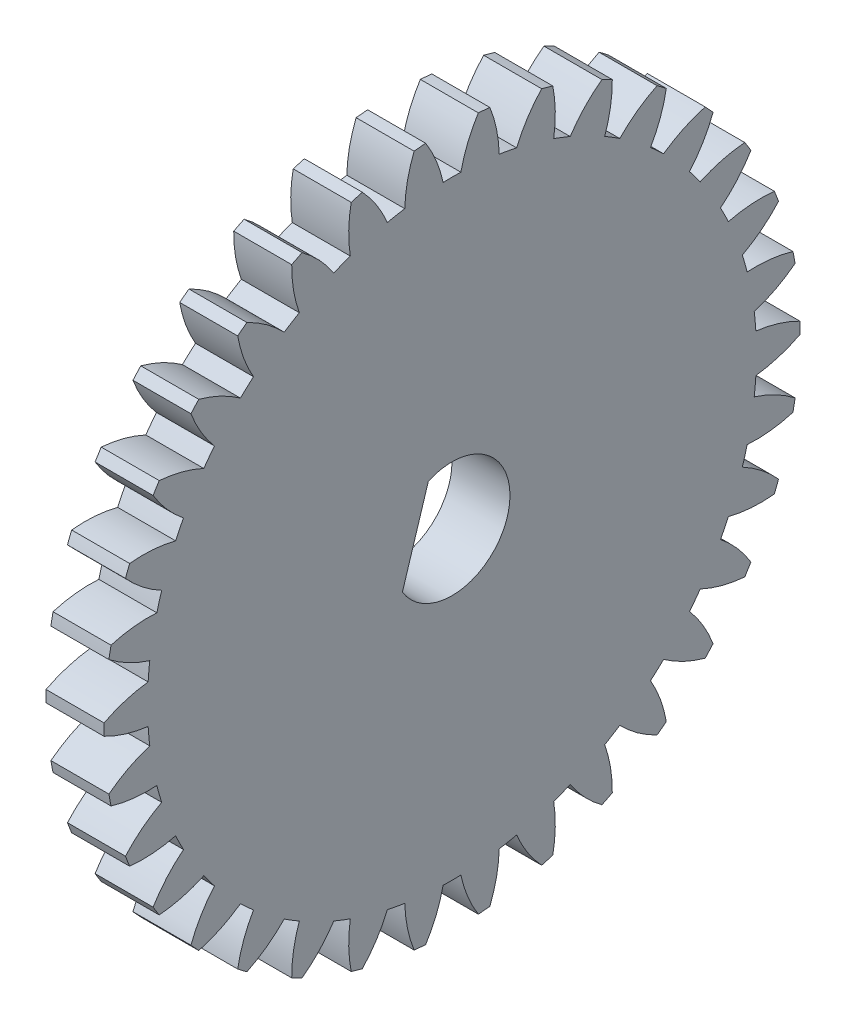
from build123d import *

# Parameters (mm, degrees)
BASPROSKE_W        = 3
BASPROSKE_H        = 18
TOOTHCUT_DEPTH     = 26.632011236
TEETHCUTS_COUNT    = 34
TEETHCUTS_ANGLE    = 349.411764706
CUT_EXTRUDE1_DEPTH = 26.595810004


with BuildPart() as part:
    # BasProSke → Base-Revolve (revolve)
    with BuildSketch(Plane(origin=(0, 0, 0), x_dir=(1, 0, 0), z_dir=(0, 1, 0)), mode=Mode.PRIVATE) as base_revolve_sk:
        with Locations((1.5, 9)):
            Rectangle(BASPROSKE_W, BASPROSKE_H)
    revolve(base_revolve_sk.sketch.rotate(Axis((-10, 0, 0), (1, 0, 0)), 180), axis=Axis((-10, 0, 0), (1, 0, 0)))

    # TooCutSke → ToothCut (cut, through all)
    with BuildSketch(Plane(origin=(0, 0, 0), x_dir=(0, 0, -1), z_dir=(1, 0, 0))):
        with BuildLine():
            ThreePointArc((0.458149848, 15.742334634), (0, 15.749), (-0.458149848, 15.742334634))
            ThreePointArc((-0.458149848, 15.742334634), (-0.818018246, 16.898604037), (-1.377276242, 17.972705843))
            ThreePointArc((-1.377276242, 17.972705843), (0, 18.0254), (1.377276242, 17.972705843))
            ThreePointArc((1.377276242, 17.972705843), (0.818018246, 16.898604037), (0.458149848, 15.742334634))
        make_face()
    toothcut = extrude(amount=TOOTHCUT_DEPTH, mode=Mode.SUBTRACT)

    # TeethCuts: ToothCut ×34 about axis
    teethcuts_axis = Axis((-10, 0, 0), (1, 0, 0))
    for i in range(1, TEETHCUTS_COUNT):
        add(toothcut.rotate(teethcuts_axis, i * TEETHCUTS_ANGLE / (TEETHCUTS_COUNT - 1)), mode=Mode.SUBTRACT)

    # Sketch1 → Cut-Extrude1 (cut, through all)
    with BuildSketch(Plane(origin=(3, 0, 0), x_dir=(0, 0, -1), z_dir=(1, 0, 0))):
        with BuildLine():
            Line((-1.223161853, 2.739320186), (-2.564939759, -1.555983301))
            ThreePointArc((-2.564939759, -1.555983301), (2.863535658, -0.894518604), (-1.223161853, 2.739320186))
        make_face()
    extrude(amount=-CUT_EXTRUDE1_DEPTH, mode=Mode.SUBTRACT)


solid = part.part
